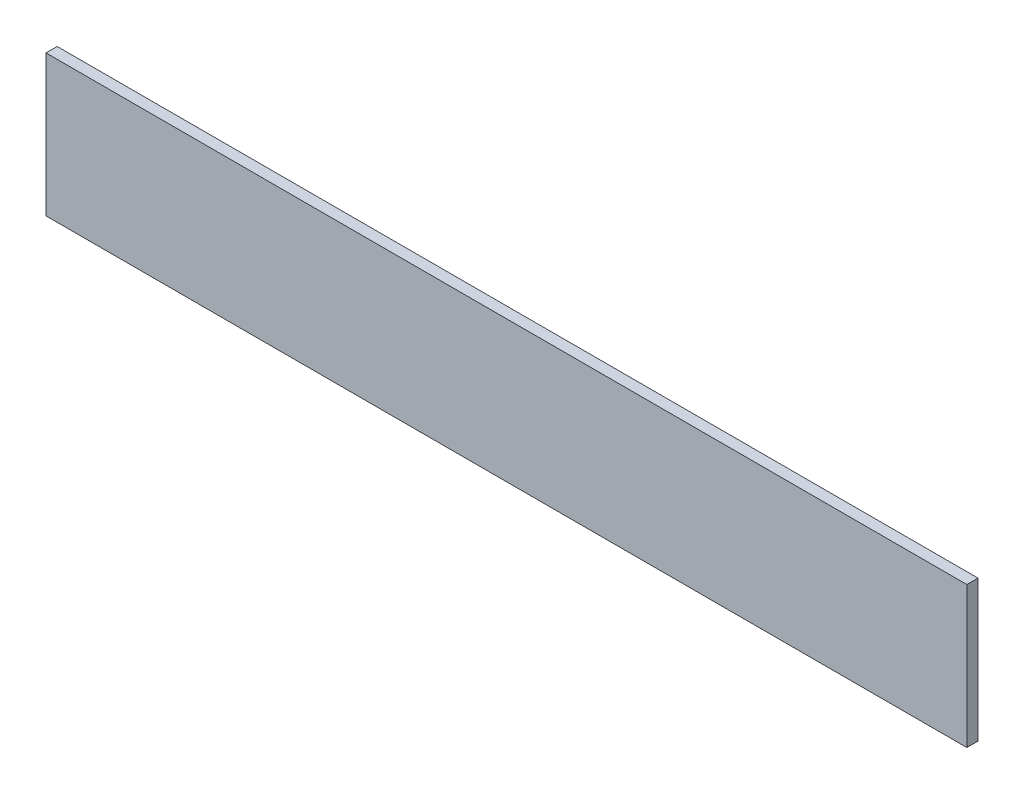
from build123d import *

# Parameters (mm, degrees)
SKETCH1_W           = 924.4
SKETCH1_H           = 141.732
BOSS_EXTRUDE1_DEPTH = 11.2


with BuildPart() as part:
    # Sketch1 → Boss-Extrude1 (new body)
    with BuildSketch(Plane.XY):
        with Locations((71.173654917, 43.612107607)):
            Rectangle(SKETCH1_W, SKETCH1_H)
    extrude(amount=BOSS_EXTRUDE1_DEPTH)


solid = part.part
